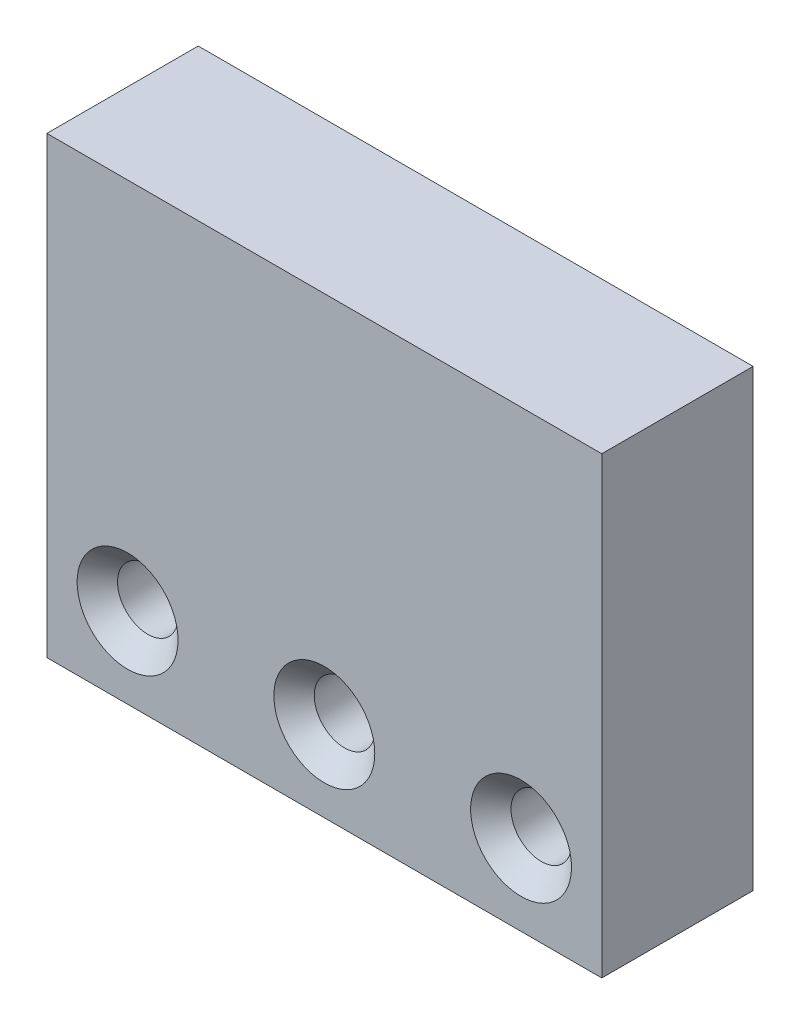
from build123d import *

# Parameters (mm, degrees)
SKETCH1_W                       = 55
SKETCH1_H                       = 45
BOSS_EXTRUDE1_DEPTH             = 7.5
F_6_0MM_DOWEL_HOLE1_D           = 6
F_6_0MM_DOWEL_HOLE1_CSINK_D     = 10
F_6_0MM_DOWEL_HOLE1_CSINK_ANGLE = 90
TAP_DRILL_FOR_M5X0_8_TAP2_D     = 4.2
TAP_DRILL_FOR_M5X0_8_TAP2_DEPTH = 10
TAP_DRILL_FOR_M5X0_8_TAP2_TIP   = 1.2618073


with BuildPart() as part:
    # Sketch1 → Boss-Extrude1 (new body, symmetric)
    with BuildSketch(Plane.XY):
        with Locations((27.5, 22.5)):
            Rectangle(SKETCH1_W, SKETCH1_H)
    extrude(amount=BOSS_EXTRUDE1_DEPTH, both=True)

    # Ø6.0mm Dowel Hole1 (through all)
    with Locations(Plane(origin=(8, 8, 7.5), x_dir=(1, 0, 0), z_dir=(0, 0, 1))):
        with Locations((0, 0), (19.5, 0), (39, 0)):
            CounterSinkHole(F_6_0MM_DOWEL_HOLE1_D / 2, F_6_0MM_DOWEL_HOLE1_CSINK_D / 2, counter_sink_angle=F_6_0MM_DOWEL_HOLE1_CSINK_ANGLE)

    # Tap Drill for M5x0.8 Tap2
    with Locations(Plane(origin=(45, 36, -7.5), x_dir=(-1, 0, 0), z_dir=(0, 0, -1))):
        with Locations((0, 0), (35, 0)):
            Hole(TAP_DRILL_FOR_M5X0_8_TAP2_D / 2, depth=TAP_DRILL_FOR_M5X0_8_TAP2_DEPTH)
            with Locations((0, 0, -(TAP_DRILL_FOR_M5X0_8_TAP2_DEPTH + TAP_DRILL_FOR_M5X0_8_TAP2_TIP / 2))):  # 118° drill point
                Cone(0, TAP_DRILL_FOR_M5X0_8_TAP2_D / 2, TAP_DRILL_FOR_M5X0_8_TAP2_TIP, mode=Mode.SUBTRACT)


solid = part.part
